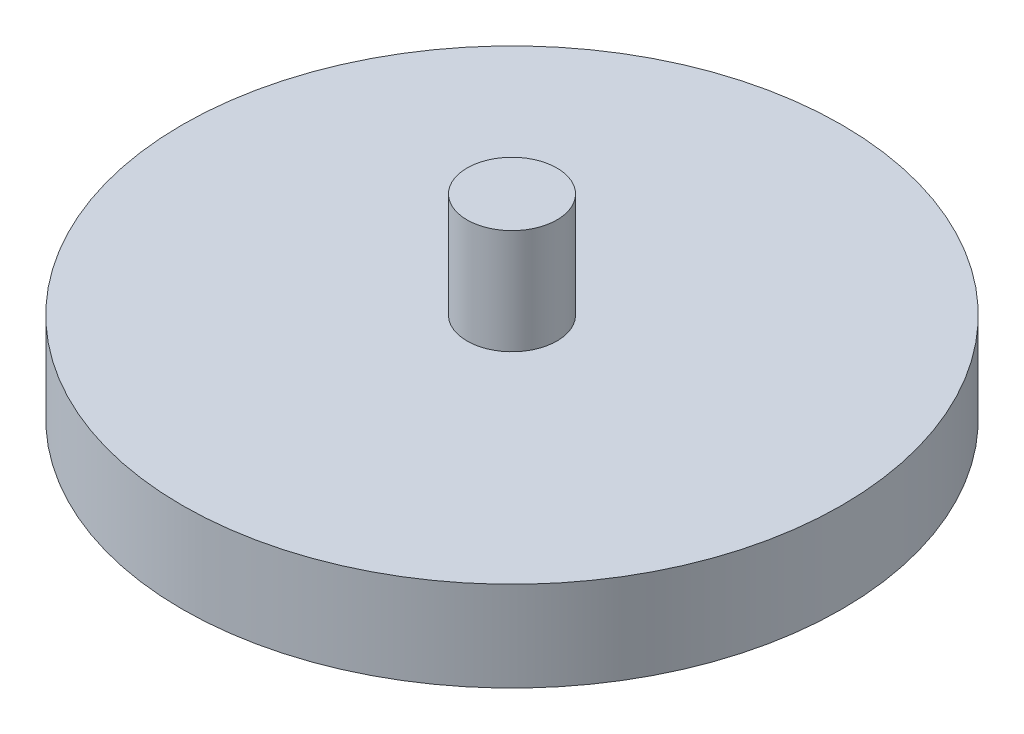
from build123d import *

# Parameters (mm, degrees)
SZKIC2_R                    = 220
DODANIE_WYCI_GNI_CIE1_DEPTH = 60
SZKIC3_R                    = 30
DODANIE_WYCI_GNI_CIE2_DEPTH = 70
SZKIC4_R                    = 30
DODANIE_WYCI_GNI_CIE3_DEPTH = 70


with BuildPart() as part:
    # Szkic2 → Dodanie-wyciągnięcie1 (new body)
    with BuildSketch(Plane(origin=(0, 0, 0), x_dir=(1, 0, 0), z_dir=(0, 1, 0))):
        Circle(SZKIC2_R)
    extrude(amount=DODANIE_WYCI_GNI_CIE1_DEPTH)

    # Szkic3 → Dodanie-wyciągnięcie2 (add)
    with BuildSketch(Plane(origin=(0, 60, 0), x_dir=(1, 0, 0), z_dir=(0, 1, 0))):
        Circle(SZKIC3_R)
    extrude(amount=DODANIE_WYCI_GNI_CIE2_DEPTH)

    # Szkic4 → Dodanie-wyciągnięcie3 (add)
    with BuildSketch(Plane.XZ):
        Circle(SZKIC4_R)
    extrude(amount=DODANIE_WYCI_GNI_CIE3_DEPTH)


solid = part.part
